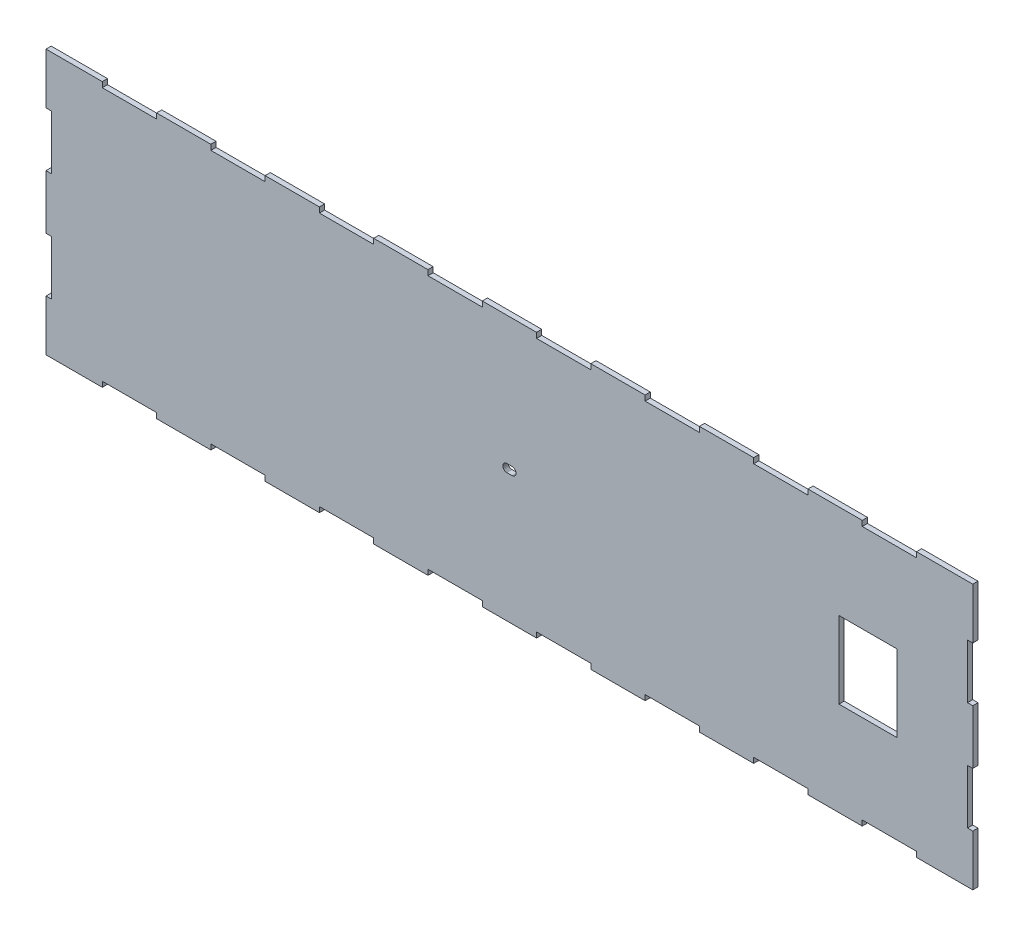
from build123d import *

# Parameters (mm, degrees)
SKETCH1_W           = 558.8
SKETCH1_H           = 736.6
BOSS_EXTRUDE1_DEPTH = 50
SCALE1_SCALE        = 0.04


with BuildPart() as part:
    # Sketch1 → Boss-Extrude1 (new body)
    with BuildSketch(Plane.XY):
        Polygon((4705.35, 2489.2), (5226.05, 2489.2), (5226.05, 2540), (5746.75, 2540), (5746.75, 2489.2), (6267.45, 2489.2), (6267.45, 2540), (6788.15, 2540), (6788.15, 2489.2), (7308.85, 2489.2), (7308.85, 2540), (7829.55, 2540), (7829.55, 2489.2), (8350.25, 2489.2), (8350.25, 2540), (8890, 2540), (8890, 2051.05), (8839.2, 2051.05), (8839.2, 1530.35), (8890, 1530.35), (8890, 1009.65), (8839.2, 1009.65), (8839.2, 488.95), (8890, 488.95), (8890, 0), (8350.25, 0), (8350.25, 50.8), (7829.55, 50.8), (7829.55, 0), (7308.85, 0), (7308.85, 50.8), (6788.15, 50.8), (6788.15, 0), (6267.45, 0), (6267.45, 50.8), (5746.75, 50.8), (5746.75, 0), (5226.05, 0), (5226.05, 50.8), (4705.35, 50.8), (4705.35, 0), (4184.65, 0), (4184.65, 50.8), (3663.95, 50.8), (3663.95, 0), (3143.25, 0), (3143.25, 50.8), (2622.55, 50.8), (2622.55, 0), (2101.85, 0), (2101.85, 50.8), (1581.15, 50.8), (1581.15, 0), (1060.45, 0), (1060.45, 50.8), (539.75, 50.8), (539.75, 0), (0, 0), (0, 488.95), (50.8, 488.95), (50.8, 1009.65), (0, 1009.65), (0, 1530.35), (50.8, 1530.35), (50.8, 2051.05), (0, 2051.05), (0, 2540), (539.75, 2540), (539.75, 2489.2), (1060.45, 2489.2), (1060.45, 2540), (1581.15, 2540), (1581.15, 2489.2), (2101.85, 2489.2), (2101.85, 2540), (2622.55, 2540), (2622.55, 2489.2), (3143.25, 2489.2), (3143.25, 2540), (3663.95, 2540), (3663.95, 2489.2), (4184.65, 2489.2), (4184.65, 2540), (4705.35, 2540), align=None)
        Polygon((4470.4, 1231.9), (4419.6, 1231.9), (4415.704496234, 1232.096705982), (4411.921521072, 1232.674056618), (4404.769760674, 1234.894086722), (4398.297927796, 1238.406881576), (4392.659231682, 1243.059231682), (4388.006881576, 1248.697927542), (4384.494086976, 1255.16976042), (4382.274056618, 1262.321521072), (4381.696705982, 1266.104496234), (4381.5, 1270), (4381.696705982, 1273.895503512), (4382.274056618, 1277.678478928), (4384.494086976, 1284.830239326), (4388.006881576, 1291.302072204), (4392.659231682, 1296.940768318), (4398.297927796, 1301.593118424), (4404.769760674, 1305.105913024), (4411.921521072, 1307.325943382), (4415.704496234, 1307.903294018), (4419.6, 1308.1), (4470.4, 1308.1), (4474.295503766, 1307.903294018), (4478.078478928, 1307.325943382), (4485.230239326, 1305.105913024), (4491.702072204, 1301.593118424), (4497.340768318, 1296.940768318), (4501.993118424, 1291.302072204), (4505.505913024, 1284.830239326), (4507.725943382, 1277.678478928), (4508.303294018, 1273.895503512), (4508.5, 1270), (4508.303294018, 1266.104496234), (4507.725943382, 1262.321521072), (4505.505913024, 1255.16976042), (4501.993118424, 1248.697927542), (4497.340768318, 1243.059231682), (4491.702072204, 1238.406881576), (4485.230239326, 1234.894086722), (4478.078478928, 1232.674056618), (4474.295503766, 1232.096705982), align=None, mode=Mode.SUBTRACT)
        with Locations((7885.605536606, 1270)):
            Rectangle(SKETCH1_W, SKETCH1_H, mode=Mode.SUBTRACT)
    extrude(amount=BOSS_EXTRUDE1_DEPTH)


with BuildPart() as part_1:
    # Scale1: scaled about (4379.531045071, 1270, 25)
    add(part.part.scale(SCALE1_SCALE).moved(Location((4204.349803268, 1219.2, 24))))


solid = part_1.part
